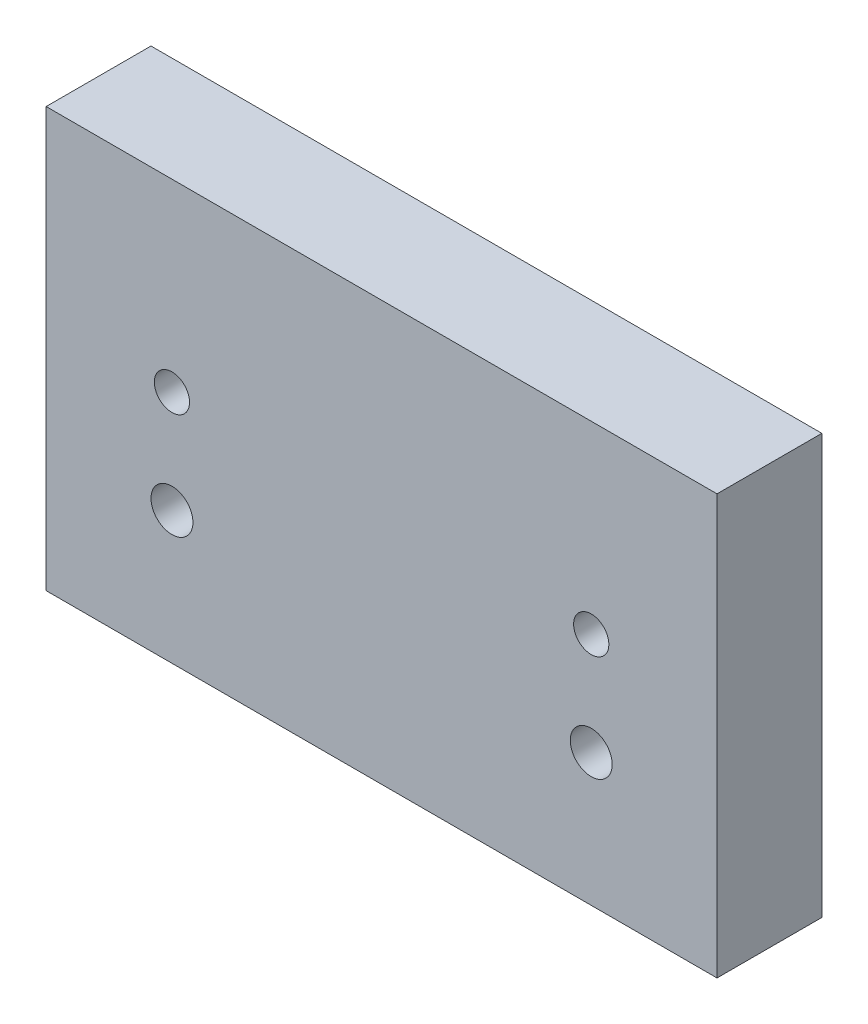
from build123d import *

# Parameters (mm, degrees)
SKETCH1_W             = 80
SKETCH1_H             = 50
EXTRUDE1_DEPTH        = 12.5
M6_TAPPED_HOLE1_D     = 5
M5_TAPPED_HOLE1_D     = 4.2
M5_TAPPED_HOLE1_DEPTH = 12.5


with BuildPart() as part:
    # Sketch1 → Extrude1 (new body)
    with BuildSketch(Plane.XY):
        Rectangle(SKETCH1_W, SKETCH1_H)
    extrude(amount=EXTRUDE1_DEPTH)

    # M6 Tapped Hole1 (through all)
    with Locations(Plane.XY.offset(12.5)):
        with Locations((-25, -9.206258577), (25, -9.206258577)):
            Hole(M6_TAPPED_HOLE1_D / 2)

    # M5 Tapped Hole1
    with Locations(Plane.XY.offset(12.5)):
        with Locations((-25, 3), (25, 3)):
            Hole(M5_TAPPED_HOLE1_D / 2, depth=M5_TAPPED_HOLE1_DEPTH)


solid = part.part
